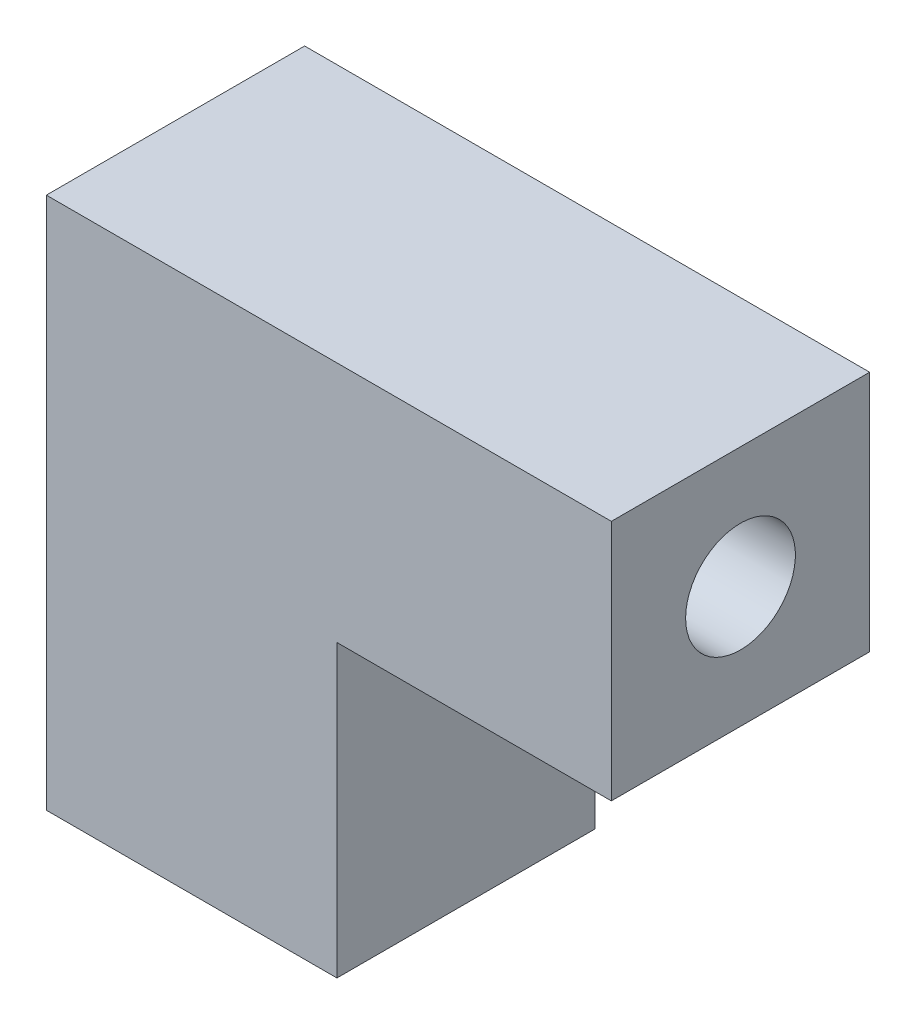
from build123d import *

# Parameters (mm, degrees)
EXTRUDE_1_DEPTH    = 8
HOLE_WIZARD_M8_1_D = 6.8


with BuildPart() as part:
    # 스케치1 → 보스-돌출1 (new body, symmetric)
    with BuildSketch(Plane.XY):
        Polygon((0, 0), (0, 33), (35, 33), (35, 18), (18, 18), (18, 0), align=None)
    extrude(amount=EXTRUDE_1_DEPTH, both=True)

    # M8 나사 구멍1 (through all)
    with Locations(Plane.ZY):
        with Locations((0, 25.5)):
            Hole(HOLE_WIZARD_M8_1_D / 2)


solid = part.part
